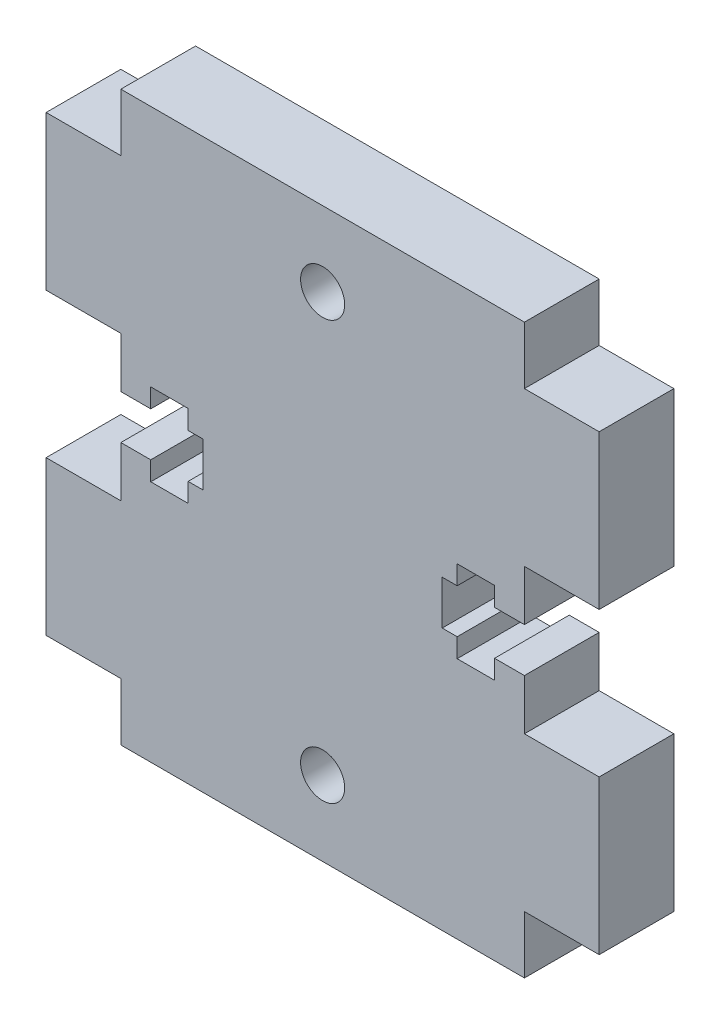
from build123d import *

# Parameters (mm, degrees)
SKETCH1_R           = 1.475
BOSS_EXTRUDE1_DEPTH = 5


with BuildPart() as part:
    # Sketch1 → Boss-Extrude1 (new body)
    with BuildSketch(Plane.XY):
        Polygon((-13.5, 19), (13.5, 19), (13.5, 15.15), (18.5, 15.15), (18.5, 4.85), (13.5, 4.85), (13.5, 1.475), (11.5, 1.475), (11.5, 2.75), (9, 2.75), (9, 1.475), (8, 1.475), (8, -1.475), (9, -1.475), (9, -2.75), (11.5, -2.75), (11.5, -1.475), (13.5, -1.475), (13.5, -4.85), (18.5, -4.85), (18.5, -15.15), (13.5, -15.15), (13.5, -19), (-13.5, -19), (-13.5, -15.15), (-18.5, -15.15), (-18.5, -4.85), (-13.5, -4.85), (-13.5, -1.475), (-11.5, -1.475), (-11.5, -2.75), (-9, -2.75), (-9, -1.475), (-8, -1.475), (-8, 1.475), (-9, 1.475), (-9, 2.75), (-11.5, 2.75), (-11.5, 1.475), (-13.5, 1.475), (-13.5, 4.85), (-18.5, 4.85), (-18.5, 15.15), (-13.5, 15.15), align=None)
        with Locations((0, 14)):
            Circle(SKETCH1_R, mode=Mode.SUBTRACT)
        with Locations((0, -14)):
            Circle(SKETCH1_R, mode=Mode.SUBTRACT)
    extrude(amount=BOSS_EXTRUDE1_DEPTH)


solid = part.part
